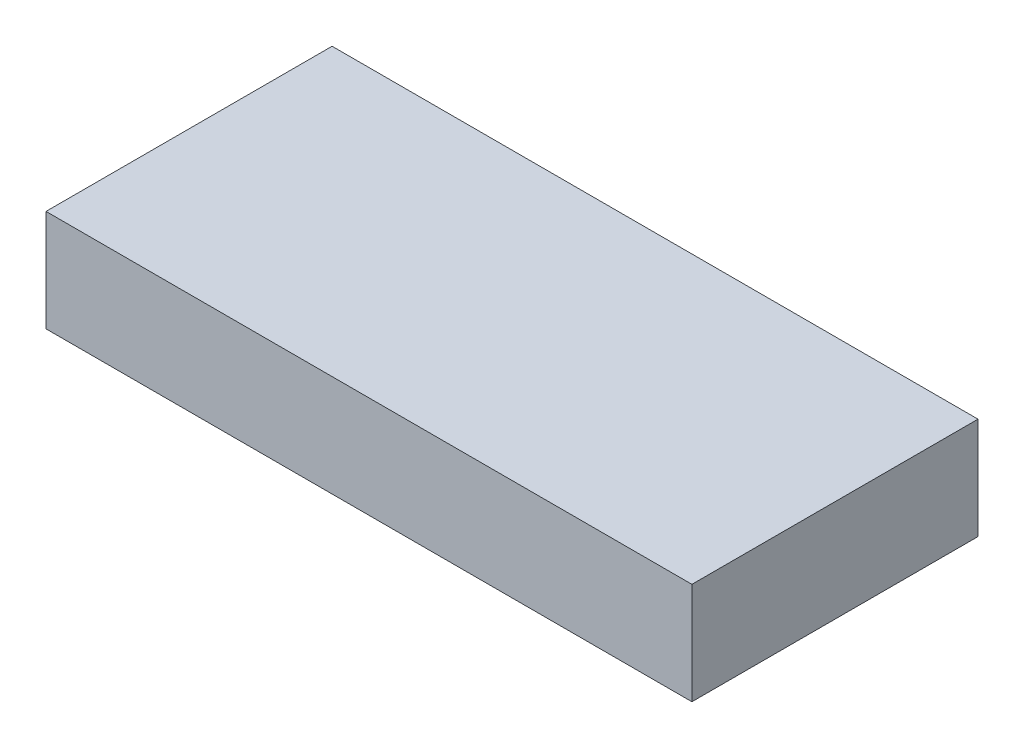
from build123d import *

# Parameters (mm, degrees)
SKETCH1_W           = 30.48
SKETCH1_H           = 13.5
BOSS_EXTRUDE1_DEPTH = 4.8


with BuildPart() as part:
    # Sketch1 → Boss-Extrude1 (new body)
    with BuildSketch(Plane(origin=(0, 0, 0), x_dir=(1, 0, 0), z_dir=(0, 1, 0))):
        Rectangle(SKETCH1_W, SKETCH1_H)
    extrude(amount=BOSS_EXTRUDE1_DEPTH)


solid = part.part
